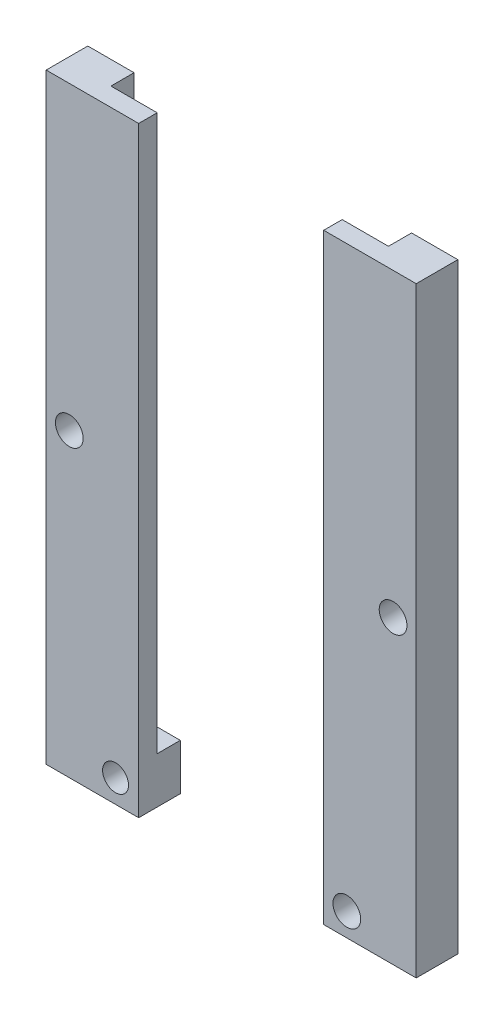
from build123d import *

# Parameters (mm, degrees)
BOSS_EXTRUDE1_DEPTH   = 4.5
BOSS_EXTRUDE1_2_DEPTH = 4.5
SKETCH2_W             = 2
SKETCH2_H             = 30
BOSS_EXTRUDE2_DEPTH   = 5
SKETCH3_W             = 2
SKETCH3_H             = 30
BOSS_EXTRUDE3_DEPTH   = 5
SKETCH4_R             = 1.401658719
SKETCH4_R_2           = 1.5
CUT_EXTRUDE1_DEPTH    = 5.5
SKETCH5_R             = 1.5
CUT_EXTRUDE2_DEPTH    = 5.5
BOSS_EXTRUDE4_DEPTH   = 30
BOSS_EXTRUDE5_DEPTH   = 30


with BuildPart() as part:
    # Sketch1 → Boss-Extrude1 (new body)
    with BuildSketch(Plane.XY):
        Polygon((-36.428241885, -97.882571264), (-36.428241885, -72.882571264), (-36.428241885, -67.882571264), (-41.428241885, -67.882571264), (-41.428241885, -72.882571264), (-41.428241885, -102.882571264), (-36.428241885, -102.882571264), (-31.428241885, -102.882571264), (-31.428241885, -97.882571264), align=None)
    extrude(amount=BOSS_EXTRUDE1_DEPTH)

    # Sketch3 → Boss-Extrude3 (add)
    with BuildSketch(Plane(origin=(-36.428241885, 0, 0), x_dir=(0, 0, -1), z_dir=(1, 0, 0))):
        with Locations((-3.5, -82.882571264)):
            Rectangle(SKETCH3_W, SKETCH3_H)
    extrude(amount=BOSS_EXTRUDE3_DEPTH)

    # Sketch4 → Cut-Extrude1 (cut, through all)
    with BuildSketch(Plane(origin=(0, 0, 0), x_dir=(-1, 0, 0), z_dir=(0, 0, -1))):
        with Locations((33.928241885, -100.382571264)):
            Circle(SKETCH4_R)
        with Locations((38.928241885, -70.382571264)):
            Circle(SKETCH4_R_2)
    extrude(amount=-CUT_EXTRUDE1_DEPTH, mode=Mode.SUBTRACT)

    # Sketch6 → Boss-Extrude4 (add)
    with BuildSketch(Plane(origin=(0, -67.882571264, 0), x_dir=(1, 0, 0), z_dir=(0, 1, 0))):
        Polygon((-36.428241885, 0), (-41.428241885, 0), (-41.428241885, -4.5), (-31.428241885, -4.5), (-31.428241885, -2.5), (-36.428241885, -2.5), align=None)
    extrude(amount=BOSS_EXTRUDE4_DEPTH)


with BuildPart() as body_2:
    # Sketch1 → Boss-Extrude1 2 (new body)
    with BuildSketch(Plane.XY):
        Polygon((-6.428241885, -97.882571264), (-6.428241885, -72.882571264), (-6.428241885, -67.882571264), (-1.428241885, -67.882571264), (-1.428241885, -72.882571264), (-1.428241885, -102.882571264), (-6.428241885, -102.882571264), (-11.428241885, -102.882571264), (-11.428241885, -97.882571264), align=None)
    extrude(amount=BOSS_EXTRUDE1_2_DEPTH)

    # Sketch2 → Boss-Extrude2 (add)
    with BuildSketch(Plane.ZY.offset(6.428241885)):
        with Locations((3.5, -82.882571264)):
            Rectangle(SKETCH2_W, SKETCH2_H)
    extrude(amount=BOSS_EXTRUDE2_DEPTH)

    # Sketch5 → Cut-Extrude2 (cut, through all)
    with BuildSketch(Plane(origin=(0, 0, 0), x_dir=(-1, 0, 0), z_dir=(0, 0, -1))):
        with Locations((8.928241885, -100.382571264)):
            Circle(SKETCH5_R)
        with Locations((3.928241885, -70.382571264)):
            Circle(SKETCH5_R)
    extrude(amount=-CUT_EXTRUDE2_DEPTH, mode=Mode.SUBTRACT)

    # Sketch7 → Boss-Extrude5 (add)
    with BuildSketch(Plane(origin=(0, -67.882571264, 0), x_dir=(1, 0, 0), z_dir=(0, 1, 0))):
        Polygon((-1.428241885, 0), (-6.428241885, 0), (-6.428241885, -2.5), (-11.428241885, -2.5), (-11.428241885, -4.5), (-1.428241885, -4.5), align=None)
    extrude(amount=BOSS_EXTRUDE5_DEPTH)


solid = Compound([part.part, body_2.part])
